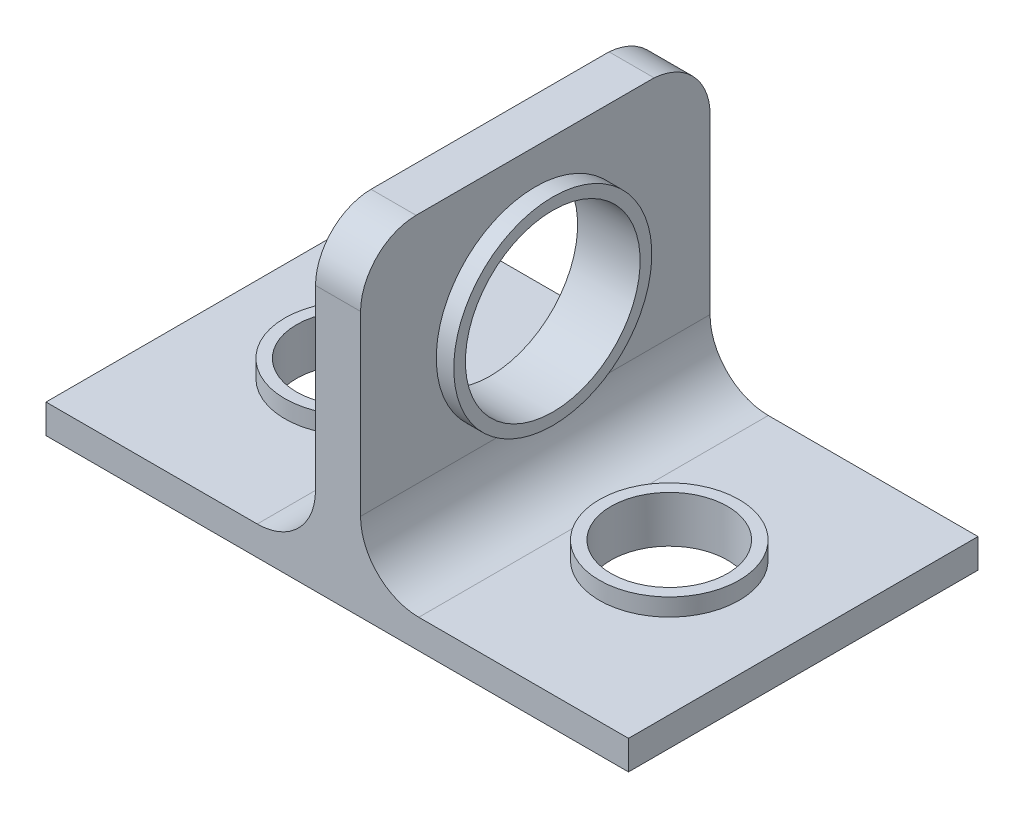
from build123d import *

# Parameters (mm, degrees)
BOSS_EXTRUDE1_DEPTH      = 60
SKETCH2_R                = 12
SKETCH2_R_2              = 10
BOSS_EXTRUDE3_DEPTH      = 3
CUT_EXTRUDE3_START       = -53
SKETCH10_R               = 10
CUT_EXTRUDE3_DEPTH       = 53
SKETCH11_5_R             = 15
CUT_EXTRUDE4_DEPTH       = 23
BOSS_EXTRUDE7_DEPTH      = 3
BOSS_EXTRUDE7_DEPTH_BACK = 3
SKETCH11_R               = 17
SKETCH11_R_2             = 15


with BuildPart() as part:
    # Sketch1 → Boss-Extrude1 (new body)
    with BuildSketch(Plane.XY):
        with BuildLine():
            Line((-47.49441662, -13.6), (52.50558338, -13.6))
            Line((52.50558338, -13.6), (52.50558338, -8.6))
            Line((52.50558338, -8.6), (16.50558338, -8.6))
            ThreePointArc((16.50558338, -8.6), (9.434515568, -5.671067812), (6.50558338, 1.4))
            Line((6.50558338, 1.4), (6.50558338, 41.4))
            Line((6.50558338, 41.4), (-1.227749954, 41.4))
            Line((-1.227749954, 41.4), (-1.227749954, 1.4))
            ThreePointArc((-1.227749954, 1.4), (-4.156682142, -5.671067812), (-11.227749954, -8.6))
            Line((-11.227749954, -8.6), (-47.49441662, -8.6))
            Line((-47.49441662, -8.6), (-47.49441662, -13.6))
        make_face()
    extrude(amount=BOSS_EXTRUDE1_DEPTH)

    # Sketch2 → Boss-Extrude3 (add)
    # profile 1 of 2: a face of its own
    with BuildSketch(Plane(origin=(0, -8.6, 0), x_dir=(1, 0, 0), z_dir=(0, 1, 0))):
        with Locations((-24.49441662, -30)):
            Circle(SKETCH2_R)
        with Locations((-24.49441662, -30)):
            Circle(SKETCH2_R_2, mode=Mode.SUBTRACT)
    # profile 2 of 2: a face of its own
    with BuildSketch(Plane(origin=(0, -8.6, 0), x_dir=(1, 0, 0), z_dir=(0, 1, 0))):
        with Locations((29.50558338, -30)):
            Circle(SKETCH2_R)
        with Locations((29.50558338, -30)):
            Circle(SKETCH2_R_2, mode=Mode.SUBTRACT)
    extrude(amount=BOSS_EXTRUDE3_DEPTH)

    # Sketch10 → Cut-Extrude3 (cut)
    with BuildSketch(Plane(origin=(0, -8.6, 0), x_dir=(1, 0, 0), z_dir=(0, 1, 0)).offset(CUT_EXTRUDE3_START)):
        with Locations((-24.49441662, -30)):
            Circle(SKETCH10_R)
        with Locations((29.50558338, -30)):
            Circle(SKETCH10_R)
    extrude(amount=CUT_EXTRUDE3_DEPTH, mode=Mode.SUBTRACT)

    # Sketch11_5 → Cut-Extrude4 (cut)
    with BuildSketch(Plane(origin=(6.50558338, 0, 0), x_dir=(0, 0, -1), z_dir=(1, 0, 0))):
        with Locations((-30, 18.4)):
            Circle(SKETCH11_5_R)
        with BuildLine():
            Line((0, 41.4), (-9.606995457, 41.4))
            ThreePointArc((-9.606995457, 41.4), (-3.020943995, 38.379056005), (0, 31.793004543))
            Line((0, 31.793004543), (0, 41.4))
        make_face()
        with BuildLine():
            Line((-60, 41.4), (-60, 31.869694824))
            ThreePointArc((-60, 31.869694824), (-57.186392619, 38.586392619), (-50.469694824, 41.4))
            Line((-50.469694824, 41.4), (-60, 41.4))
        make_face()
    extrude(amount=-CUT_EXTRUDE4_DEPTH, mode=Mode.SUBTRACT)

    # Sketch11 → Boss-Extrude7 (add, two sides: drawn at the far end of the back side and taken through both)
    with BuildSketch(Plane(origin=(6.50558338, 0, 0), x_dir=(0, 0, -1), z_dir=(1, 0, 0)).offset(-BOSS_EXTRUDE7_DEPTH_BACK)):
        with Locations((-30, 18.4)):
            Circle(SKETCH11_R)
        with Locations((-30, 18.4)):
            Circle(SKETCH11_R_2, mode=Mode.SUBTRACT)
    extrude(amount=BOSS_EXTRUDE7_DEPTH + BOSS_EXTRUDE7_DEPTH_BACK)


solid = part.part
